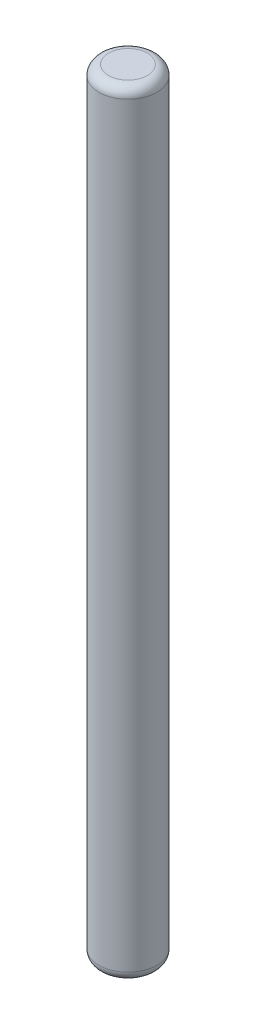
from build123d import *

# Parameters (mm, degrees)
SKETCH2_R           = 1.5
BOSS_EXTRUDE1_DEPTH = 40
FILLET1_R           = 0.5


with BuildPart() as part:
    # Sketch2 → Boss-Extrude1 (new body)
    with BuildSketch(Plane(origin=(0, 0, 0), x_dir=(1, 0, 0), z_dir=(0, 1, 0))):
        Circle(SKETCH2_R)
    extrude(amount=BOSS_EXTRUDE1_DEPTH)

    # Fillet1
    fillet1_edges = [part.edges().sort_by_distance(p)[0] for p in [
        (-1.5, 0, 0),
        (-1.5, 40, 0),
    ]]
    fillet(fillet1_edges, radius=FILLET1_R)


solid = part.part
